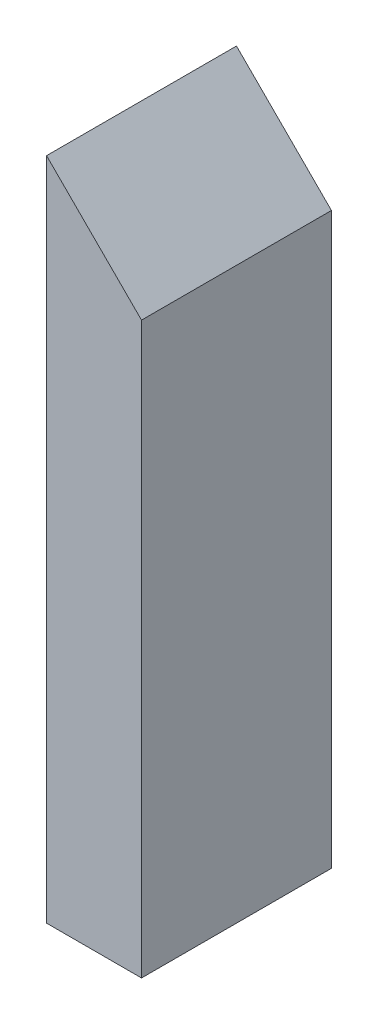
from build123d import *

# Parameters (mm, degrees)
ESTRUSIONE_ESTRUSIONE1_DEPTH = 20


with BuildPart() as part:
    # Schizzo1 → Estrusione-Estrusione1 (new body)
    with BuildSketch(Plane.XY):
        Polygon((5, 0), (-5, 10), (-5, 0), (-5, -60), (5, -60), align=None)
    extrude(amount=ESTRUSIONE_ESTRUSIONE1_DEPTH)


solid = part.part
